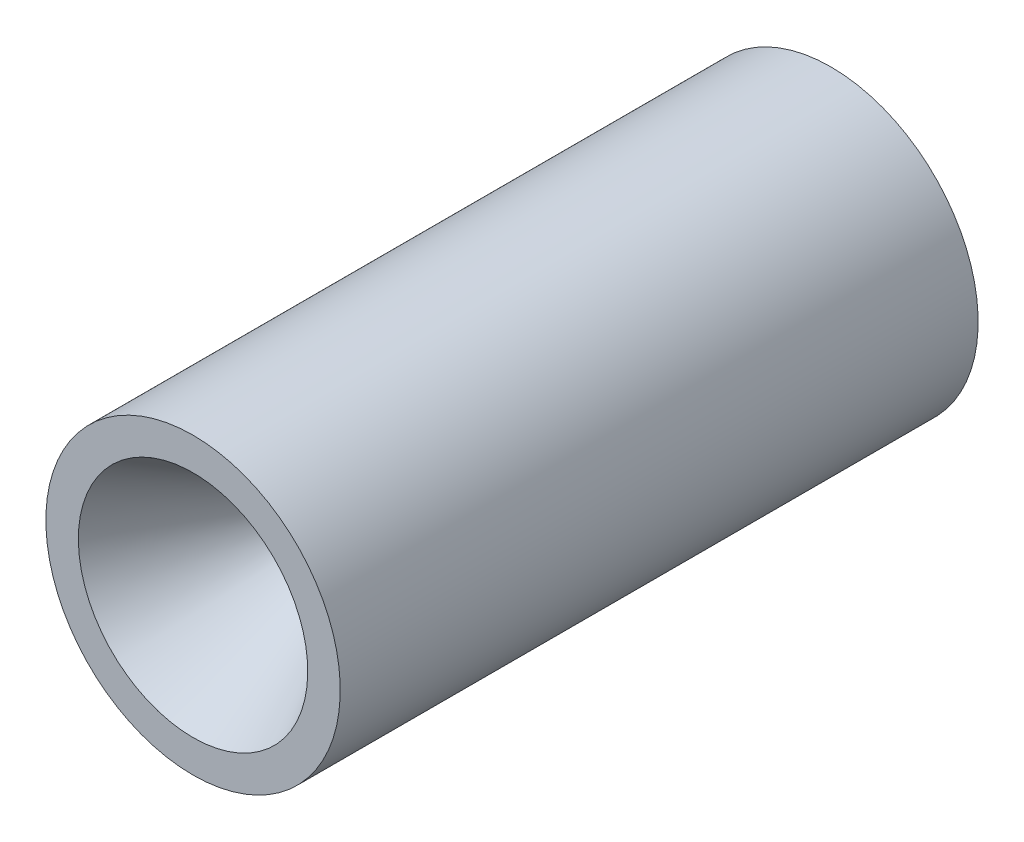
from build123d import *


with BuildPart() as part:
    # Sketch1 → Revolve2 (revolve)
    with BuildSketch(Plane(origin=(0, 0, 0), x_dir=(0, 0, -1), z_dir=(1, 0, 0))):
        Polygon((-62.980861169, 29.688958151), (-28.055861169, 9.525), (-24.880861169, 9.525), (102.119138831, 33.02), (102.119138831, 38.1), (-62.980861169, 38.1), align=None)
    revolve(axis=Axis((0, 0, 62.980861169), (0, 0, -1)))


solid = part.part
